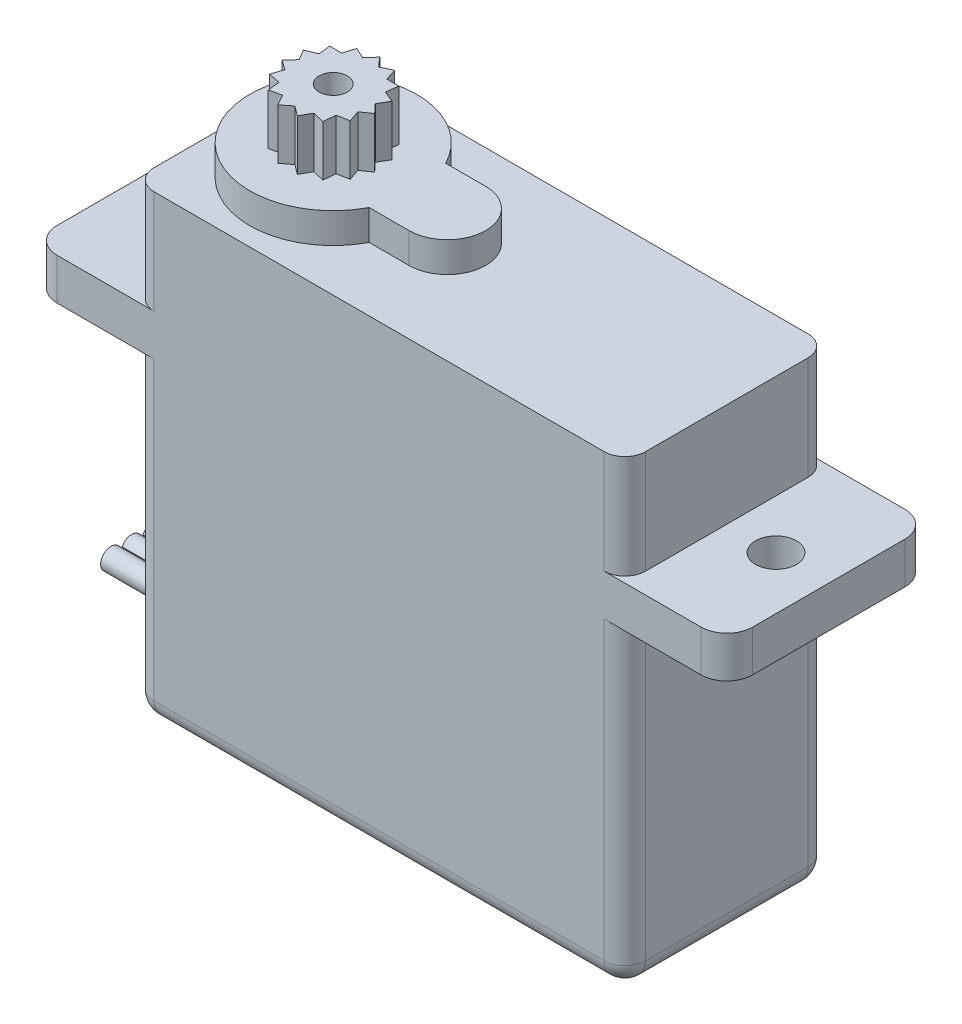
from build123d import *

# Parameters (mm, degrees)
BOSS_EXTRUDE1_DEPTH = 4.925
BOSS_EXTRUDE3_DEPTH = 1.46
SKETCH6_R           = 0.68
BOSS_EXTRUDE4_DEPTH = 2.45
SKETCH2_R           = 0.99
CUT_EXTRUDE6_DEPTH  = 10
FILLET1_R           = 1
FILLET2_R           = 1.25
BOSS_EXTRUDE5_DEPTH = 5


with BuildPart() as part:
    # Sketch1 → Boss-Extrude1 (new, symmetric)
    with BuildSketch(Plane.XY):
        Polygon((0, 0), (0, 15.3), (-4.925, 15.3), (-4.925, 17.3), (0, 17.3), (0, 22.3), (23.75, 22.3), (23.75, 17.3), (28.675, 17.3), (28.675, 15.3), (23.75, 15.3), (23.75, 0), align=None)
    extrude(amount=BOSS_EXTRUDE1_DEPTH, both=True)

    # Sketch5 → Boss-Extrude3 (add)
    with BuildSketch(Plane(origin=(0, 22.3, 0), x_dir=(1, 0, 0), z_dir=(0, 1, 0))):
        with BuildLine():
            Line((10.25, 1.85), (8.32090644, 1.85))
            ThreePointArc((8.32090644, 1.85), (0.7, 0), (8.32090644, -1.85))
            Line((8.32090644, -1.85), (10.25, -1.85))
            ThreePointArc((10.25, -1.85), (12.1, 0), (10.25, 1.85))
        make_face()
    extrude(amount=BOSS_EXTRUDE3_DEPTH)

    # Sketch6 → Boss-Extrude4 (add)
    with BuildSketch(Plane(origin=(0, 23.76, 0), x_dir=(1, 0, 0), z_dir=(0, 1, 0))):
        Polygon((4.350363372, 1.809573061), (4.735, 2.25), (5.119636628, 1.809573061), (5.650157447, 2.05547728), (5.822402717, 1.49668144), (6.407075857, 1.505543864), (6.337146997, 0.925), (6.874877162, 0.695288237), (6.574865506, 0.193377657), (6.972674265, -0.235189042), (6.494454555, -0.57168144), (6.683557159, -1.125), (6.109817927, -1.237891622), (6.057516818, -1.820288237), (5.48746279, -1.690059097), (5.202801304, -2.200832102), (4.735, -1.85), (4.267198696, -2.200832102), (3.98253721, -1.690059097), (3.412483182, -1.820288237), (3.360182073, -1.237891622), (2.786442841, -1.125), (2.975545445, -0.57168144), (2.497325735, -0.235189042), (2.895134494, 0.193377657), (2.595122838, 0.695288237), (3.132853003, 0.925), (3.062924143, 1.505543864), (3.647597283, 1.49668144), (3.819842553, 2.05547728), align=None)
        with Locations((4.735, 0)):
            Circle(SKETCH6_R, mode=Mode.SUBTRACT)
    extrude(amount=BOSS_EXTRUDE4_DEPTH)

    # Sketch2 → Cut-Extrude6 (cut)
    with BuildSketch(Plane(origin=(0, 17.3, 0), x_dir=(1, 0, 0), z_dir=(0, 1, 0))):
        with Locations((-2.375, 0)):
            Circle(SKETCH2_R)
        with Locations((26.125, 0)):
            Circle(SKETCH2_R)
    extrude(amount=-CUT_EXTRUDE6_DEPTH, mode=Mode.SUBTRACT)

    # Fillet1
    fillet1_edges = [part.edges().sort_by_distance(p)[0] for p in [
        (0, 0, 0),
        (11.875, 0, 4.925),
        (23.75, 0, 0),
        (11.875, 0, -4.925),
        (0, 7.65, -4.925),
        (0, 19.8, -4.925),
        (0, 7.65, 4.925),
        (0, 19.8, 4.925),
        (23.75, 19.8, 4.925),
        (23.75, 19.8, -4.925),
        (23.75, 7.65, -4.925),
        (23.75, 7.65, 4.925),
    ]]
    fillet(fillet1_edges, radius=FILLET1_R)

    # Fillet2
    fillet2_edges = [part.edges().sort_by_distance(p)[0] for p in [
        (28.675, 16.3, -4.925),
        (-4.925, 16.3, -4.925),
        (-4.925, 16.3, 4.925),
        (28.675, 16.3, 4.925),
    ]]
    fillet(fillet2_edges, radius=FILLET2_R)

    # Sketch7 → Boss-Extrude5 (add)
    with BuildSketch(Plane.ZY):
        with BuildLine():
            Line((-0.543660539, 2.20433868), (-0.456339461, 2.20433868))
            ThreePointArc((-0.456339461, 2.20433868), (0, 2.5), (0.456339461, 2.20433868))
            Line((0.456339461, 2.20433868), (0.543660539, 2.20433868))
            ThreePointArc((0.543660539, 2.20433868), (1.5, 2), (0.543660539, 1.79566132))
            Line((0.543660539, 1.79566132), (0.456339461, 1.79566132))
            ThreePointArc((0.456339461, 1.79566132), (0, 1.5), (-0.456339461, 1.79566132))
            Line((-0.456339461, 1.79566132), (-0.543660539, 1.79566132))
            ThreePointArc((-0.543660539, 1.79566132), (-1.5, 2), (-0.543660539, 2.20433868))
        make_face()
    extrude(amount=BOSS_EXTRUDE5_DEPTH)


solid = part.part
